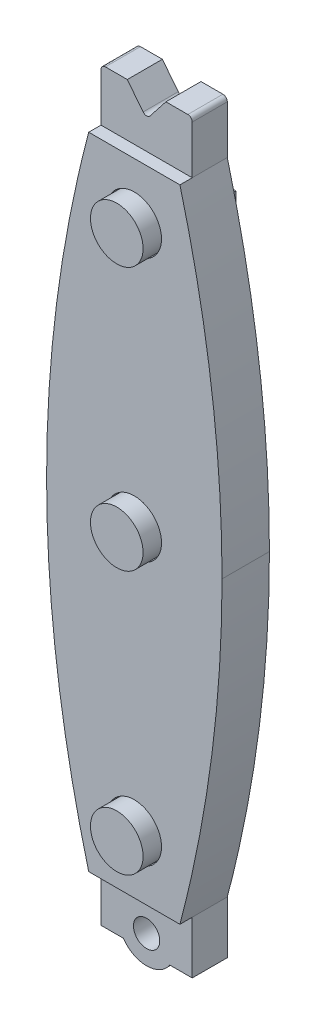
from build123d import *

# Parameters (mm, degrees)
SKETCH1_W           = 25.4
SKETCH1_H           = 92.71
BOSS_EXTRUDE1_DEPTH = 5.08
SKETCH3_W           = 13.208
SKETCH3_H           = 5.08
BOSS_EXTRUDE3_DEPTH = 11.938
SKETCH5_R           = 1.905
CUT_EXTRUDE2_DEPTH  = 6.08
SKETCH7_W           = 25.4
SKETCH7_H           = 92.71
BOSS_EXTRUDE4_DEPTH = 1.778
SKETCH8_R           = 3.937
CUT_EXTRUDE3_DEPTH  = 1.27
SKETCH10_R          = 3.81
BOSS_EXTRUDE5_DEPTH = 3.81
SKETCH11_W          = 13.208
SKETCH11_H          = 5.08
BOSS_EXTRUDE6_DEPTH = 7.62
CUT_EXTRUDE4_DEPTH  = 6.08
FILLET1_R           = 0.635
CUT_EXTRUDE7_DEPTH  = 7.62
CUT_EXTRUDE8_DEPTH  = 7.8580001
SKETCH17_W          = 12.7
SKETCH17_H          = 82.55
BOSS_EXTRUDE7_DEPTH = 1.524


with BuildPart() as part:
    # Sketch1 → Boss-Extrude1 (new body)
    with BuildSketch(Plane.XY):
        with Locations((-20.361983471, -4.405640496)):
            Rectangle(SKETCH1_W, SKETCH1_H)
    extrude(amount=BOSS_EXTRUDE1_DEPTH)

    # Sketch3 → Boss-Extrude3 (add)
    with BuildSketch(Plane.XZ.offset(50.760640496)):
        with Locations((-20.361983471, 2.54)):
            Rectangle(SKETCH3_W, SKETCH3_H)
    extrude(amount=BOSS_EXTRUDE3_DEPTH)

    # Sketch5 → Cut-Extrude2 (cut, through all)
    with BuildSketch(Plane.XY.offset(5.08)):
        with Locations((-20.361983471, -56.094640496)):
            Circle(SKETCH5_R)
        with BuildLine():
            Line((-23.722087636, -58.380640496), (-26.965983471, -58.380640496))
            Line((-26.965983471, -58.380640496), (-26.965983471, -62.698640496))
            Line((-26.965983471, -62.698640496), (-13.757983471, -62.698640496))
            Line((-13.757983471, -62.698640496), (-13.757983471, -58.380640496))
            Line((-13.757983471, -58.380640496), (-17.001879306, -58.380640496))
            ThreePointArc((-17.001879306, -58.380640496), (-20.361983471, -60.158640496), (-23.722087636, -58.380640496))
        make_face()
    extrude(amount=-CUT_EXTRUDE2_DEPTH, mode=Mode.SUBTRACT)

    # Sketch7 → Boss-Extrude4 (add)
    with BuildSketch(Plane.XY.offset(5.08)):
        with Locations((-20.361983471, -4.405640496)):
            Rectangle(SKETCH7_W, SKETCH7_H)
    extrude(amount=BOSS_EXTRUDE4_DEPTH)

    # Sketch8 → Cut-Extrude3 (cut)
    with BuildSketch(Plane.XY.offset(6.858)):
        with Locations((-20.361983471, -42.378640496)):
            Circle(SKETCH8_R)
        with Locations((-20.361983471, -4.278640496)):
            Circle(SKETCH8_R)
        with Locations((-20.361983471, 33.821359504)):
            Circle(SKETCH8_R)
    extrude(amount=-CUT_EXTRUDE3_DEPTH, mode=Mode.SUBTRACT)

    # Sketch10 → Boss-Extrude5 (add)
    with BuildSketch(Plane.XY.offset(5.588)):
        with Locations((-20.361983471, -42.378640496)):
            Circle(SKETCH10_R)
        with Locations((-20.361983471, -4.278640496)):
            Circle(SKETCH10_R)
        with Locations((-20.361983471, 33.821359504)):
            Circle(SKETCH10_R)
    extrude(amount=BOSS_EXTRUDE5_DEPTH)

    # Sketch11 → Boss-Extrude6 (add)
    with BuildSketch(Plane(origin=(0, 41.949359504, 0), x_dir=(1, 0, 0), z_dir=(0, 1, 0))):
        with Locations((-20.361983471, -2.54)):
            Rectangle(SKETCH11_W, SKETCH11_H)
    extrude(amount=BOSS_EXTRUDE6_DEPTH)

    # Sketch12 → Cut-Extrude4 (cut, through all)
    with BuildSketch(Plane.XY.offset(5.08)):
        Polygon((-23.155983471, 49.569359504), (-20.361983471, 46.013359504), (-17.567983471, 49.569359504), align=None)
    extrude(amount=-CUT_EXTRUDE4_DEPTH, mode=Mode.SUBTRACT)

    # Fillet1
    fillet1_edges = [part.edges().sort_by_distance(p)[0] for p in [
        (-26.965983471, 49.569359504, 2.54),
        (-13.757983471, 49.569359504, 2.54),
        (-20.361983471, 46.013359504, 2.54),
    ]]
    fillet(fillet1_edges, radius=FILLET1_R)

    # Sketch14 → Cut-Extrude7 (cut)
    with BuildSketch(Plane.XY.offset(6.858)):
        with BuildLine():
            Line((-13.757983471, 41.949359504), (-7.661983471, 41.949359504))
            Line((-7.661983471, 41.949359504), (-7.661983471, -4.405640496))
            add(Edge.make_bspline(
                [(-13.757983471, 41.949359504), (-7.661983471, 18.771859504), (-7.661983471, -4.405640496)],
                knots=[0, 0, 0, 0.5, 0.5, 0.5], degree=2))
        make_face()
        with BuildLine():
            Line((-33.061983471, -4.405640496), (-33.061983471, 41.949359504))
            Line((-33.061983471, 41.949359504), (-26.965983471, 41.949359504))
            add(Edge.make_bspline(
                [(-26.965983471, 41.949359504), (-33.061983471, 18.771859504), (-33.061983471, -4.405640496)],
                knots=[0, 0, 0, 0.5, 0.5, 0.5], degree=2))
        make_face()
    extrude(amount=-CUT_EXTRUDE7_DEPTH, mode=Mode.SUBTRACT)

    # Sketch16 → Cut-Extrude8 (cut, through all)
    with BuildSketch(Plane.XY.offset(6.858)):
        with BuildLine():
            Line((-33.061983471, -4.405640496), (-33.061983471, -50.760640496))
            Line((-33.061983471, -50.760640496), (-26.965983471, -50.760640496))
            add(Edge.make_bspline(
                [(-33.061983471, -4.405640496), (-33.061983471, -27.583140496), (-26.965983471, -50.760640496)],
                knots=[0.5, 0.5, 0.5, 1, 1, 1], degree=2))
        make_face()
        with BuildLine():
            Line((-7.661983471, -4.405640496), (-7.661983471, -50.760640496))
            Line((-7.661983471, -50.760640496), (-13.757983471, -50.760640496))
            add(Edge.make_bspline(
                [(-13.757983471, -50.760640496), (-7.661983471, -27.583140496), (-7.661983471, -4.405640496)],
                knots=[0, 0, 0, 0.5, 0.5, 0.5], degree=2))
        make_face()
    extrude(amount=-CUT_EXTRUDE8_DEPTH, mode=Mode.SUBTRACT)

    # Sketch17 → Boss-Extrude7 (add)
    with BuildSketch(Plane(origin=(0, 0, 0), x_dir=(-1, 0, 0), z_dir=(0, 0, -1))):
        with Locations((20.361983471, -4.405640496)):
            Rectangle(SKETCH17_W, SKETCH17_H)
    extrude(amount=BOSS_EXTRUDE7_DEPTH)


solid = part.part
